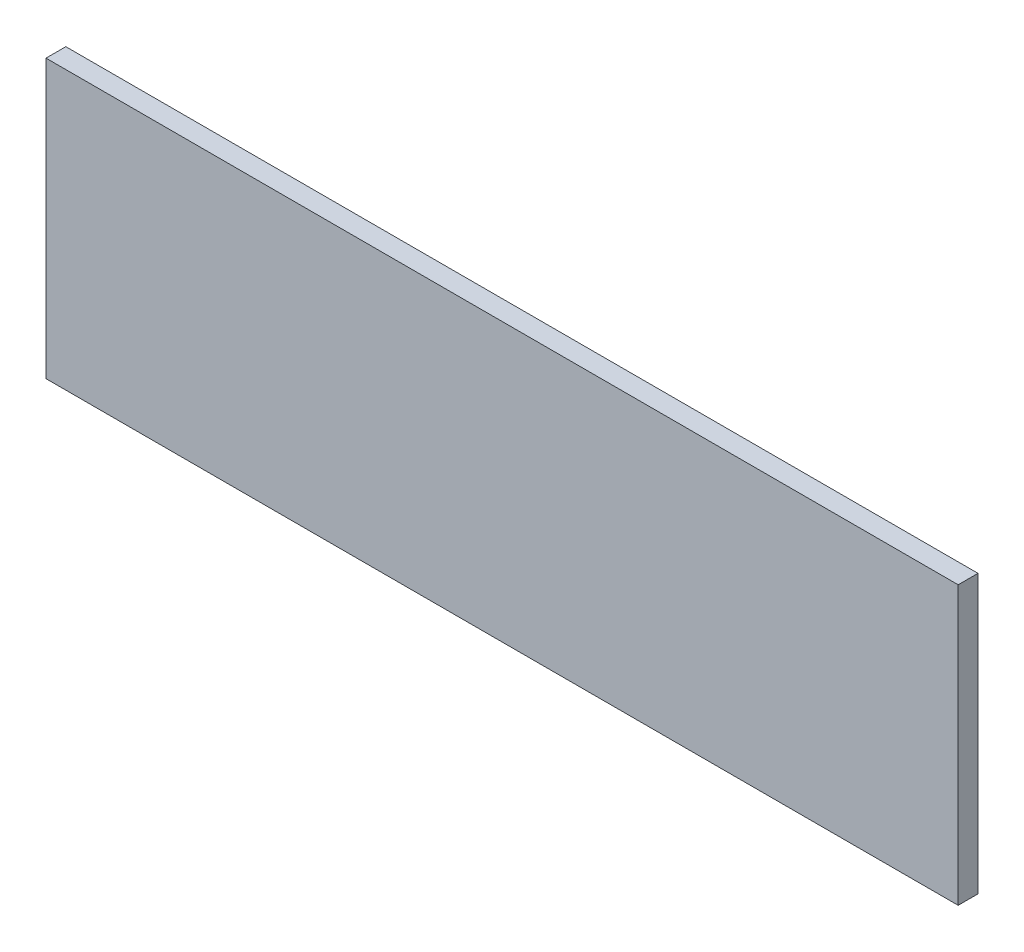
from build123d import *

# Parameters (mm, degrees)
SKETCH1_W           = 292.1
SKETCH1_H           = 88.9
BOSS_EXTRUDE1_DEPTH = 6.35


with BuildPart() as part:
    # Sketch1 → Boss-Extrude1 (new body)
    with BuildSketch(Plane.XY):
        with Locations((146.05, 44.45)):
            Rectangle(SKETCH1_W, SKETCH1_H)
    extrude(amount=BOSS_EXTRUDE1_DEPTH)


solid = part.part
